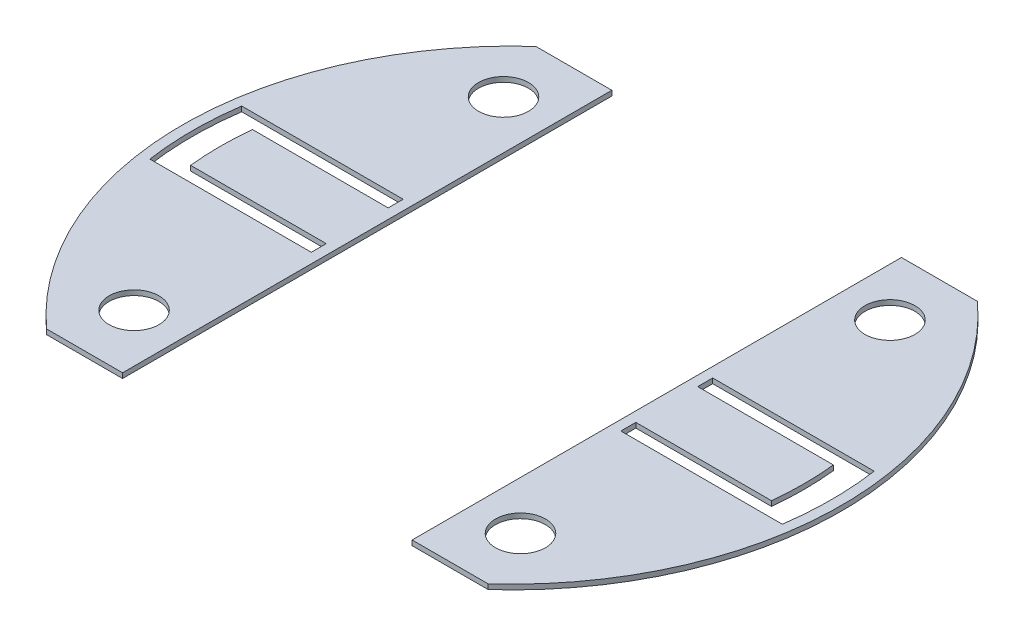
from build123d import *

# Parameters (mm, degrees)
BOSS_EXTRUDE1_DEPTH   = 0.254
BOSS_EXTRUDE1_2_DEPTH = 0.254
SKETCH2_R             = 1.27
CUT_EXTRUDE1_DEPTH    = 1.254


with BuildPart() as part:
    # Sketch1 → Boss-Extrude1 (new body)
    with BuildSketch(Plane(origin=(0, 0, 0), x_dir=(1, 0, 0), z_dir=(0, 1, 0))):
        with BuildLine():
            Line((11.230707012, -12.446), (7.366, -12.446))
            Line((7.366, -12.446), (7.366, 12.446))
            Line((7.366, 12.446), (11.230707012, 12.446))
            ThreePointArc((11.230707012, 12.446), (16.764, 0), (11.230707012, -12.446))
        make_face()
        with BuildLine():
            Line((7.874, -1.5748), (14.775313396, -1.5748))
            ThreePointArc((14.775313396, -1.5748), (14.859, 0), (14.775313396, 1.5748))
            Line((14.775313396, 1.5748), (7.874, 1.5748))
            Line((7.874, 1.5748), (7.874, 2.3368))
            Line((7.874, 2.3368), (16.087165747, 2.3368))
            ThreePointArc((16.087165747, 2.3368), (16.256, 0), (16.087165747, -2.3368))
            Line((16.087165747, -2.3368), (7.874, -2.3368))
            Line((7.874, -2.3368), (7.874, -1.5748))
        make_face(mode=Mode.SUBTRACT)
    extrude(amount=BOSS_EXTRUDE1_DEPTH)


with BuildPart() as body_2:
    # Sketch1 → Boss-Extrude1 2 (new body)
    with BuildSketch(Plane(origin=(0, 0, 0), x_dir=(1, 0, 0), z_dir=(0, 1, 0))):
        with BuildLine():
            Line((-11.230707012, 12.446), (-7.366, 12.446))
            Line((-7.366, 12.446), (-7.366, -12.446))
            Line((-7.366, -12.446), (-11.230707012, -12.446))
            ThreePointArc((-11.230707012, -12.446), (-16.764, 0), (-11.230707012, 12.446))
        make_face()
        with BuildLine():
            ThreePointArc((-14.775313396, -1.5748), (-14.859, 0), (-14.775313396, 1.5748))
            Line((-14.775313396, 1.5748), (-7.874, 1.5748))
            Line((-7.874, 1.5748), (-7.874, 2.3368))
            Line((-7.874, 2.3368), (-16.087165747, 2.3368))
            ThreePointArc((-16.087165747, 2.3368), (-16.256, 0), (-16.087165747, -2.3368))
            Line((-16.087165747, -2.3368), (-7.874, -2.3368))
            Line((-7.874, -2.3368), (-7.874, -1.5748))
            Line((-7.874, -1.5748), (-14.775313396, -1.5748))
        make_face(mode=Mode.SUBTRACT)
    extrude(amount=BOSS_EXTRUDE1_2_DEPTH)


with BuildPart() as cut_extrude1_tool:
    # Sketch2 → Cut-Extrude1 (new body, through all)
    with BuildSketch(Plane(origin=(0, 0.254, 0), x_dir=(1, 0, 0), z_dir=(0, 1, 0))):
        with Locations((9.8298, -9.398)):
            Circle(SKETCH2_R)
        with Locations((9.8298, 9.398)):
            Circle(SKETCH2_R)
        with Locations((-9.8298, -9.398)):
            Circle(SKETCH2_R)
        with Locations((-9.8298, 9.398)):
            Circle(SKETCH2_R)
    extrude(amount=-CUT_EXTRUDE1_DEPTH)


with BuildPart() as part_1:
    add(part.part)

    # Cut-Extrude1: cut by cut_extrude1_tool
    add(cut_extrude1_tool.part, mode=Mode.SUBTRACT)


with BuildPart() as body_2_1:
    add(body_2.part)

    # Cut-Extrude1: cut by cut_extrude1_tool
    add(cut_extrude1_tool.part, mode=Mode.SUBTRACT)


solid = Compound([part_1.part, body_2_1.part])
